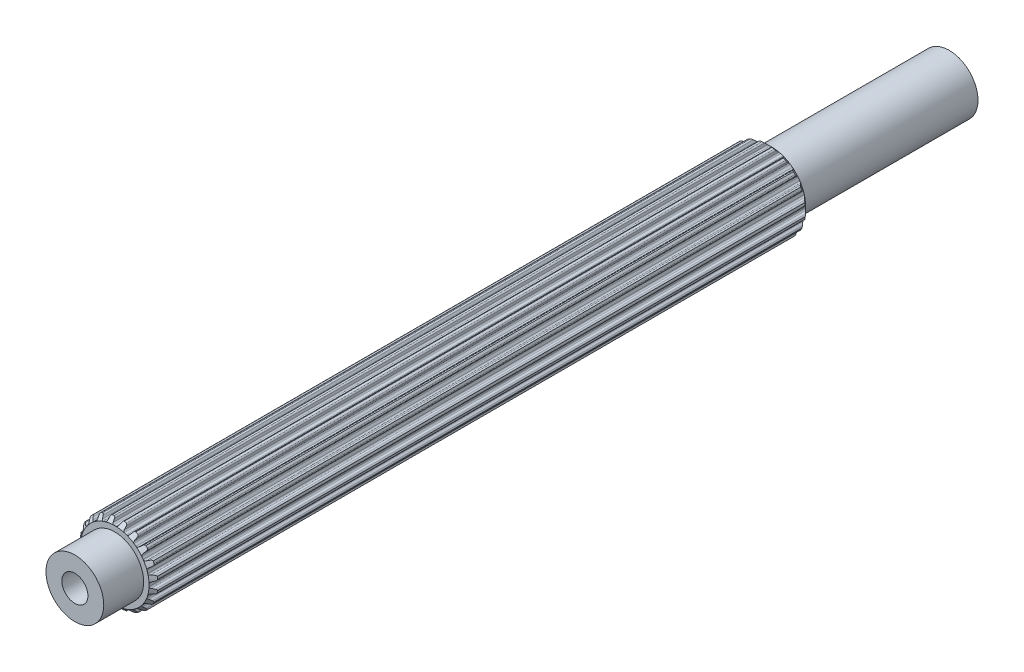
from build123d import *

# Parameters (mm, degrees)
BOSS_EXTRUDE1_DEPTH            = 34.37509
BOSS_EXTRUDE1_DEPTH_BACK       = 22.43709
SKETCH2_R                      = 2.5019
BOSS_EXTRUDE2_DEPTH            = 37.82949
CUT_EXTRUDE1_REACH             = 39.829
SKETCH7_R                      = 1.1303
CUT_EXTRUDE1_DIRECTION_2_REACH = 39.829
SKETCH8_R                      = 1.1303
BOSS_EXTRUDE3_DEPTH            = 28.30449
BOSS_EXTRUDE3_DEPTH_BACK       = 28.30449


with BuildPart() as part:
    # Sketch1 → Boss-Extrude1 (new body, two sides)
    with BuildSketch(Plane.XY) as boss_extrude1_sk:
        with BuildLine():
            Line((-0.106949245, 2.969874934), (0.106949245, 2.969874934))
            ThreePointArc((0.106949245, 2.969874934), (0.196343213, 2.986924176), (0.253739238, 3.057547504))
            Line((0.253739238, 3.057547504), (0.315888147, 3.237526941))
            ThreePointArc((0.315888147, 3.237526941), (0.359032156, 3.298322911), (0.4281449, 3.326269005))
            Line((0.4281449, 3.326269005), (0.620027588, 3.2937547))
            ThreePointArc((0.620027588, 3.2937547), (0.689621142, 3.24802576), (0.718272212, 3.169836791))
            Line((0.718272212, 3.169836791), (0.724389167, 2.979527391))
            ThreePointArc((0.724389167, 2.979527391), (0.750934762, 2.9040661), (0.816027049, 2.857568043))
            Line((0.816027049, 2.857568043), (1.019456602, 2.791469774))
            ThreePointArc((1.019456602, 2.791469774), (1.109743823, 2.780060312), (1.186154496, 2.829490741))
            Line((1.186154496, 2.829490741), (1.300878326, 2.981456288))
            ThreePointArc((1.300878326, 2.981456288), (1.360697704, 3.02594446), (1.435063648, 3.031165762))
            Line((1.435063648, 3.031165762), (1.607507455, 2.940947809))
            ThreePointArc((1.607507455, 2.940947809), (1.659563839, 2.875951412), (1.662650905, 2.792735615))
            Line((1.662650905, 2.792735615), (1.609659636, 2.609850378))
            ThreePointArc((1.609659636, 2.609850378), (1.611587176, 2.529879385), (1.659124931, 2.465542482))
            Line((1.659124931, 2.465542482), (1.832172444, 2.339816104))
            ThreePointArc((1.832172444, 2.339816104), (1.914514976, 2.301064775), (2.002460687, 2.32446371))
            Line((2.002460687, 2.32446371), (2.158529469, 2.433539921))
            ThreePointArc((2.158529469, 2.433539921), (2.229168681, 2.457365482), (2.301508367, 2.439350895))
            Line((2.301508367, 2.439350895), (2.437633293, 2.300260456))
            ThreePointArc((2.437633293, 2.300260456), (2.467056864, 2.222358901), (2.444277744, 2.14226202))
            Line((2.444277744, 2.14226202), (2.337365406, 1.984703026))
            ThreePointArc((2.337365406, 1.984703026), (2.314486209, 1.908050449), (2.339816104, 1.832172444))
            Line((2.339816104, 1.832172444), (2.465542482, 1.659124931))
            ThreePointArc((2.465542482, 1.659124931), (2.531880064, 1.596824985), (2.622752074, 1.591901975))
            Line((2.622752074, 1.591901975), (2.804888709, 1.64741171))
            ThreePointArc((2.804888709, 1.64741171), (2.879433095, 1.648242449), (2.942665411, 1.608755366))
            Line((2.942665411, 1.608755366), (3.0291466, 1.434407582))
            ThreePointArc((3.0291466, 1.434407582), (3.033057175, 1.351226417), (2.986641646, 1.282088892))
            Line((2.986641646, 1.282088892), (2.836273564, 1.165279113))
            ThreePointArc((2.836273564, 1.165279113), (2.790827206, 1.099448241), (2.791469774, 1.019456602))
            Line((2.791469774, 1.019456602), (2.857568043, 0.816027049))
            ThreePointArc((2.857568043, 0.816027049), (2.901407091, 0.736276839), (2.986310214, 0.703513784))
            Line((2.986310214, 0.703513784), (3.1766859, 0.700023363))
            ThreePointArc((3.1766859, 0.700023363), (3.247838536, 0.677777961), (3.295773863, 0.620683653))
            Line((3.295773863, 0.620683653), (3.324145932, 0.4281449))
            ThreePointArc((3.324145932, 0.4281449), (3.302160717, 0.347826477), (3.236652255, 0.29641597))
            Line((3.236652255, 0.29641597), (3.057547504, 0.231789562))
            ThreePointArc((3.057547504, 0.231789562), (2.993982591, 0.183224379), (2.969874934, 0.106949245))
            Line((2.969874934, 0.106949245), (2.969874934, -0.106949245))
            ThreePointArc((2.969874934, -0.106949245), (2.986924176, -0.196343213), (3.057547504, -0.253739238))
            Line((3.057547504, -0.253739238), (3.237526941, -0.315888147))
            ThreePointArc((3.237526941, -0.315888147), (3.298322911, -0.359032156), (3.326269005, -0.4281449))
            Line((3.326269005, -0.4281449), (3.2937547, -0.620027588))
            ThreePointArc((3.2937547, -0.620027588), (3.24802576, -0.689621142), (3.169836791, -0.718272212))
            Line((3.169836791, -0.718272212), (2.979527391, -0.724389167))
            ThreePointArc((2.979527391, -0.724389167), (2.9040661, -0.750934762), (2.857568043, -0.816027049))
            Line((2.857568043, -0.816027049), (2.791469774, -1.019456602))
            ThreePointArc((2.791469774, -1.019456602), (2.780060312, -1.109743823), (2.829490741, -1.186154496))
            Line((2.829490741, -1.186154496), (2.981456288, -1.300878326))
            ThreePointArc((2.981456288, -1.300878326), (3.02594446, -1.360697704), (3.031165762, -1.435063648))
            Line((3.031165762, -1.435063648), (2.940947809, -1.607507455))
            ThreePointArc((2.940947809, -1.607507455), (2.875951412, -1.659563839), (2.792735615, -1.662650905))
            Line((2.792735615, -1.662650905), (2.609850378, -1.609659636))
            ThreePointArc((2.609850378, -1.609659636), (2.529879385, -1.611587176), (2.465542482, -1.659124931))
            Line((2.465542482, -1.659124931), (2.339816104, -1.832172444))
            ThreePointArc((2.339816104, -1.832172444), (2.301064775, -1.914514976), (2.32446371, -2.002460687))
            Line((2.32446371, -2.002460687), (2.433539921, -2.158529469))
            ThreePointArc((2.433539921, -2.158529469), (2.457365482, -2.229168681), (2.439350895, -2.301508367))
            Line((2.439350895, -2.301508367), (2.300260456, -2.437633293))
            ThreePointArc((2.300260456, -2.437633293), (2.222358901, -2.467056864), (2.14226202, -2.444277744))
            Line((2.14226202, -2.444277744), (1.984703026, -2.337365406))
            ThreePointArc((1.984703026, -2.337365406), (1.908050449, -2.314486209), (1.832172444, -2.339816104))
            Line((1.832172444, -2.339816104), (1.659124931, -2.465542482))
            ThreePointArc((1.659124931, -2.465542482), (1.596824985, -2.531880064), (1.591901975, -2.622752074))
            Line((1.591901975, -2.622752074), (1.64741171, -2.804888709))
            ThreePointArc((1.64741171, -2.804888709), (1.648242449, -2.879433095), (1.608755366, -2.942665411))
            Line((1.608755366, -2.942665411), (1.434407582, -3.0291466))
            ThreePointArc((1.434407582, -3.0291466), (1.351226417, -3.033057175), (1.282088892, -2.986641646))
            Line((1.282088892, -2.986641646), (1.165279113, -2.836273564))
            ThreePointArc((1.165279113, -2.836273564), (1.099448241, -2.790827206), (1.019456602, -2.791469774))
            Line((1.019456602, -2.791469774), (0.816027049, -2.857568043))
            ThreePointArc((0.816027049, -2.857568043), (0.736276839, -2.901407091), (0.703513784, -2.986310214))
            Line((0.703513784, -2.986310214), (0.700023363, -3.1766859))
            ThreePointArc((0.700023363, -3.1766859), (0.677777961, -3.247838536), (0.620683653, -3.295773863))
            Line((0.620683653, -3.295773863), (0.4281449, -3.324145932))
            ThreePointArc((0.4281449, -3.324145932), (0.347826477, -3.302160717), (0.29641597, -3.236652255))
            Line((0.29641597, -3.236652255), (0.231789562, -3.057547504))
            ThreePointArc((0.231789562, -3.057547504), (0.183224379, -2.993982591), (0.106949245, -2.969874934))
            Line((0.106949245, -2.969874934), (-0.106949245, -2.969874934))
            ThreePointArc((-0.106949245, -2.969874934), (-0.196343213, -2.986924176), (-0.253739238, -3.057547504))
            Line((-0.253739238, -3.057547504), (-0.315888147, -3.237526941))
            ThreePointArc((-0.315888147, -3.237526941), (-0.359032156, -3.298322911), (-0.4281449, -3.326269005))
            Line((-0.4281449, -3.326269005), (-0.620027588, -3.2937547))
            ThreePointArc((-0.620027588, -3.2937547), (-0.689621142, -3.24802576), (-0.718272212, -3.169836791))
            Line((-0.718272212, -3.169836791), (-0.724389167, -2.979527391))
            ThreePointArc((-0.724389167, -2.979527391), (-0.750934762, -2.9040661), (-0.816027049, -2.857568043))
            Line((-0.816027049, -2.857568043), (-1.019456602, -2.791469774))
            ThreePointArc((-1.019456602, -2.791469774), (-1.109743823, -2.780060312), (-1.186154496, -2.829490741))
            Line((-1.186154496, -2.829490741), (-1.300878326, -2.981456288))
            ThreePointArc((-1.300878326, -2.981456288), (-1.360697704, -3.02594446), (-1.435063648, -3.031165762))
            Line((-1.435063648, -3.031165762), (-1.607507455, -2.940947809))
            ThreePointArc((-1.607507455, -2.940947809), (-1.659563839, -2.875951412), (-1.662650905, -2.792735615))
            Line((-1.662650905, -2.792735615), (-1.609659636, -2.609850378))
            ThreePointArc((-1.609659636, -2.609850378), (-1.611587176, -2.529879385), (-1.659124931, -2.465542482))
            Line((-1.659124931, -2.465542482), (-1.832172444, -2.339816104))
            ThreePointArc((-1.832172444, -2.339816104), (-1.914514976, -2.301064775), (-2.002460687, -2.32446371))
            Line((-2.002460687, -2.32446371), (-2.158529469, -2.433539921))
            ThreePointArc((-2.158529469, -2.433539921), (-2.229168681, -2.457365482), (-2.301508367, -2.439350895))
            Line((-2.301508367, -2.439350895), (-2.437633293, -2.300260456))
            ThreePointArc((-2.437633293, -2.300260456), (-2.467056864, -2.222358901), (-2.444277744, -2.14226202))
            Line((-2.444277744, -2.14226202), (-2.337365406, -1.984703026))
            ThreePointArc((-2.337365406, -1.984703026), (-2.314486209, -1.908050449), (-2.339816104, -1.832172444))
            Line((-2.339816104, -1.832172444), (-2.465542482, -1.659124931))
            ThreePointArc((-2.465542482, -1.659124931), (-2.531880064, -1.596824985), (-2.622752074, -1.591901975))
            Line((-2.622752074, -1.591901975), (-2.804888709, -1.64741171))
            ThreePointArc((-2.804888709, -1.64741171), (-2.879433095, -1.648242449), (-2.942665411, -1.608755366))
            Line((-2.942665411, -1.608755366), (-3.0291466, -1.434407582))
            ThreePointArc((-3.0291466, -1.434407582), (-3.033057175, -1.351226417), (-2.986641646, -1.282088892))
            Line((-2.986641646, -1.282088892), (-2.836273564, -1.165279113))
            ThreePointArc((-2.836273564, -1.165279113), (-2.790827206, -1.099448241), (-2.791469774, -1.019456602))
            Line((-2.791469774, -1.019456602), (-2.857568043, -0.816027049))
            ThreePointArc((-2.857568043, -0.816027049), (-2.901407091, -0.736276839), (-2.986310214, -0.703513784))
            Line((-2.986310214, -0.703513784), (-3.1766859, -0.700023363))
            ThreePointArc((-3.1766859, -0.700023363), (-3.247838536, -0.677777961), (-3.295773863, -0.620683653))
            Line((-3.295773863, -0.620683653), (-3.324145932, -0.4281449))
            ThreePointArc((-3.324145932, -0.4281449), (-3.302160717, -0.347826477), (-3.236652255, -0.29641597))
            Line((-3.236652255, -0.29641597), (-3.057547504, -0.231789562))
            ThreePointArc((-3.057547504, -0.231789562), (-2.993982591, -0.183224379), (-2.969874934, -0.106949245))
            Line((-2.969874934, -0.106949245), (-2.969874934, 0.106949245))
            ThreePointArc((-2.969874934, 0.106949245), (-2.986924176, 0.196343213), (-3.057547504, 0.253739238))
            Line((-3.057547504, 0.253739238), (-3.237526941, 0.315888147))
            ThreePointArc((-3.237526941, 0.315888147), (-3.298322911, 0.359032156), (-3.326269005, 0.4281449))
            Line((-3.326269005, 0.4281449), (-3.2937547, 0.620027588))
            ThreePointArc((-3.2937547, 0.620027588), (-3.24802576, 0.689621142), (-3.169836791, 0.718272212))
            Line((-3.169836791, 0.718272212), (-2.979527391, 0.724389167))
            ThreePointArc((-2.979527391, 0.724389167), (-2.9040661, 0.750934762), (-2.857568043, 0.816027049))
            Line((-2.857568043, 0.816027049), (-2.791469774, 1.019456602))
            ThreePointArc((-2.791469774, 1.019456602), (-2.780060312, 1.109743823), (-2.829490741, 1.186154496))
            Line((-2.829490741, 1.186154496), (-2.981456288, 1.300878326))
            ThreePointArc((-2.981456288, 1.300878326), (-3.02594446, 1.360697704), (-3.031165762, 1.435063648))
            Line((-3.031165762, 1.435063648), (-2.940947809, 1.607507455))
            ThreePointArc((-2.940947809, 1.607507455), (-2.875951412, 1.659563839), (-2.792735615, 1.662650905))
            Line((-2.792735615, 1.662650905), (-2.609850378, 1.609659636))
            ThreePointArc((-2.609850378, 1.609659636), (-2.529879385, 1.611587176), (-2.465542482, 1.659124931))
            Line((-2.465542482, 1.659124931), (-2.339816104, 1.832172444))
            ThreePointArc((-2.339816104, 1.832172444), (-2.301064775, 1.914514976), (-2.32446371, 2.002460687))
            Line((-2.32446371, 2.002460687), (-2.433539921, 2.158529469))
            ThreePointArc((-2.433539921, 2.158529469), (-2.457365482, 2.229168681), (-2.439350895, 2.301508367))
            Line((-2.439350895, 2.301508367), (-2.300260456, 2.437633293))
            ThreePointArc((-2.300260456, 2.437633293), (-2.222358901, 2.467056864), (-2.14226202, 2.444277744))
            Line((-2.14226202, 2.444277744), (-1.984703026, 2.337365406))
            ThreePointArc((-1.984703026, 2.337365406), (-1.908050449, 2.314486209), (-1.832172444, 2.339816104))
            Line((-1.832172444, 2.339816104), (-1.659124931, 2.465542482))
            ThreePointArc((-1.659124931, 2.465542482), (-1.596824985, 2.531880064), (-1.591901975, 2.622752074))
            Line((-1.591901975, 2.622752074), (-1.64741171, 2.804888709))
            ThreePointArc((-1.64741171, 2.804888709), (-1.648242449, 2.879433095), (-1.608755366, 2.942665411))
            Line((-1.608755366, 2.942665411), (-1.434407582, 3.0291466))
            ThreePointArc((-1.434407582, 3.0291466), (-1.351226417, 3.033057175), (-1.282088892, 2.986641646))
            Line((-1.282088892, 2.986641646), (-1.165279113, 2.836273564))
            ThreePointArc((-1.165279113, 2.836273564), (-1.099448241, 2.790827206), (-1.019456602, 2.791469774))
            Line((-1.019456602, 2.791469774), (-0.816027049, 2.857568043))
            ThreePointArc((-0.816027049, 2.857568043), (-0.736276839, 2.901407091), (-0.703513784, 2.986310214))
            Line((-0.703513784, 2.986310214), (-0.700023363, 3.1766859))
            ThreePointArc((-0.700023363, 3.1766859), (-0.677777961, 3.247838536), (-0.620683653, 3.295773863))
            Line((-0.620683653, 3.295773863), (-0.4281449, 3.324145932))
            ThreePointArc((-0.4281449, 3.324145932), (-0.347826477, 3.302160717), (-0.29641597, 3.236652255))
            Line((-0.29641597, 3.236652255), (-0.231789562, 3.057547504))
            ThreePointArc((-0.231789562, 3.057547504), (-0.183224379, 2.993982591), (-0.106949245, 2.969874934))
        make_face()
    extrude(amount=BOSS_EXTRUDE1_DEPTH)
    extrude(boss_extrude1_sk.sketch, amount=-BOSS_EXTRUDE1_DEPTH_BACK)

    # Sketch2 → Boss-Extrude2 (add, symmetric)
    with BuildSketch(Plane.XY):
        Circle(SKETCH2_R)
    extrude(amount=BOSS_EXTRUDE2_DEPTH, both=True)

    # Sketch3 → Cut-Revolve1 (revolve, cut)
    with BuildSketch(Plane(origin=(0, 0, 0), x_dir=(0, 0, -1), z_dir=(1, 0, 0))):
        Polygon((-33.243865505, 4.101099429), (-34.37509, 2.969874934), (-34.37509, 4.101099429), align=None)
        Polygon((22.43709, 19.150959155), (22.43709, 2.969874934), (14.346547889, 11.060417045), align=None)
    revolve(axis=Axis((0, 0, 14.360793934), (0, 0, -1)), mode=Mode.SUBTRACT)

    # Cut-Extrude1: up to this face of the body (flat: up to its plane)
    cut_extrude1_end = Plane(part.part.faces().sort_by_distance((0, 0, 37.82949))[0])
    # Sketch7 → Cut-Extrude1 (cut, up to the picked face)
    with BuildSketch(Plane.XY, mode=Mode.PRIVATE) as cut_extrude1_sk1:
        Circle(SKETCH7_R)
    cut_extrude1_tool1 = split(extrude(cut_extrude1_sk1.sketch, amount=CUT_EXTRUDE1_REACH, mode=Mode.PRIVATE), bisect_by=cut_extrude1_end, keep=Keep.BOTH, mode=Mode.PRIVATE)
    add(cut_extrude1_tool1.solids().sort_by_distance((0, 0, 0))[0], mode=Mode.SUBTRACT)

    # Cut-Extrude1 direction 2: up to this face of the body (flat: up to its plane)
    cut_extrude1_direction_2_end = Plane(part.part.faces().sort_by_distance((0, 0, -37.82949))[0])
    # Sketch7 → Cut-Extrude1 direction 2 (cut, up to the picked face)
    with BuildSketch(Plane.XY, mode=Mode.PRIVATE) as cut_extrude1_direction_2_sk1:
        Circle(SKETCH7_R)
    cut_extrude1_direction_2_tool1 = split(extrude(cut_extrude1_direction_2_sk1.sketch, amount=-CUT_EXTRUDE1_DIRECTION_2_REACH, mode=Mode.PRIVATE), bisect_by=cut_extrude1_direction_2_end, keep=Keep.BOTH, mode=Mode.PRIVATE)
    add(cut_extrude1_direction_2_tool1.solids().sort_by_distance((0, 0, 0))[0], mode=Mode.SUBTRACT)

    # Sketch8 → Boss-Extrude3 (add, two sides)
    with BuildSketch(Plane.XY) as boss_extrude3_sk:
        Circle(SKETCH8_R)
    extrude(amount=BOSS_EXTRUDE3_DEPTH)
    extrude(boss_extrude3_sk.sketch, amount=-BOSS_EXTRUDE3_DEPTH_BACK)


solid = part.part
